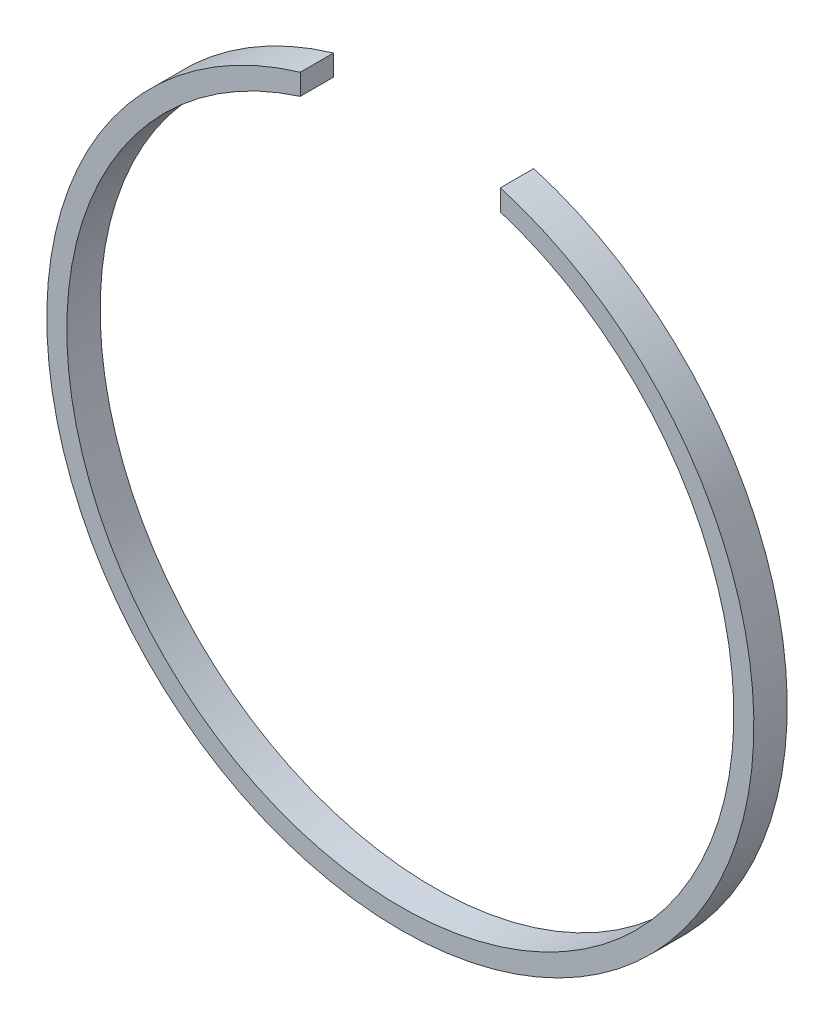
from build123d import *

# Parameters (mm, degrees)
SKETCH_1_R          = 53
SKETCH_1_R_2        = 50
EXTRUDE_1_DEPTH     = 5
SKETCH_2_W          = 30
SKETCH_2_H          = 30
CUT_EXTRUDE_1_DEPTH = 10


with BuildPart() as part:
    # 草图1 → 拉伸-薄壁1 (new body)
    with BuildSketch(Plane.XY):
        Circle(SKETCH_1_R)
        Circle(SKETCH_1_R_2, mode=Mode.SUBTRACT)
    extrude(amount=EXTRUDE_1_DEPTH)

    # 草图2 → 切除-拉伸1 (cut)
    with BuildSketch(Plane.XY.offset(5)):
        with Locations((0, 50)):
            Rectangle(SKETCH_2_W, SKETCH_2_H)
    extrude(amount=-CUT_EXTRUDE_1_DEPTH, mode=Mode.SUBTRACT)


solid = part.part
